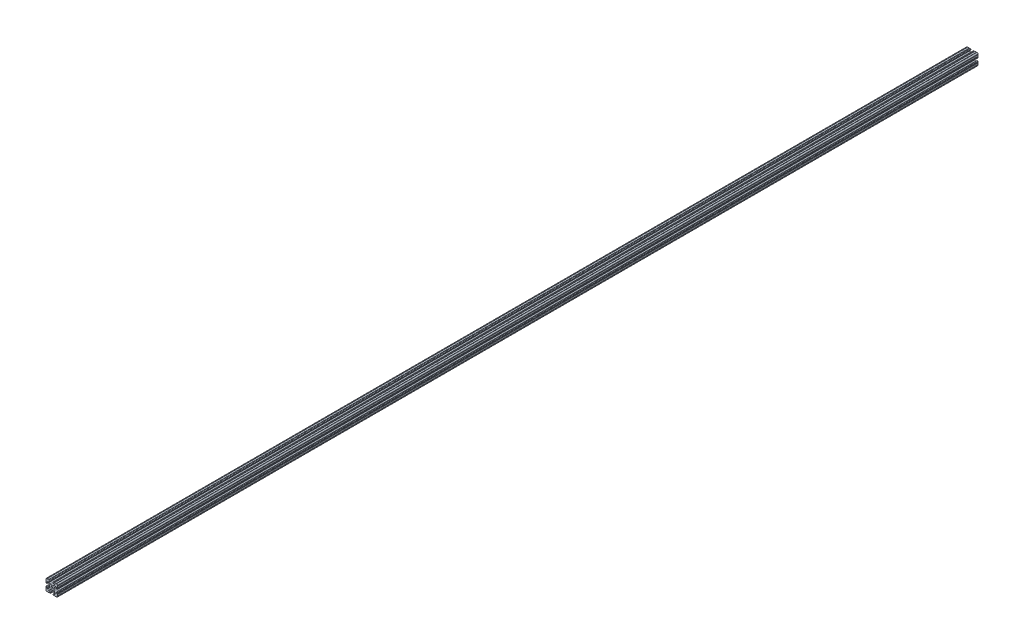
from build123d import *

# Parameters (mm, degrees)
SKETCH1_R           = 3.3274
BOSS_EXTRUDE1_DEPTH = 3048


with BuildPart() as part:
    # Sketch1 → Boss-Extrude1 (new body)
    with BuildSketch(Plane(origin=(0, 0, -304.8), x_dir=(-1, 0, 0), z_dir=(0, 0, -1))):
        with BuildLine():
            Line((14.327719208, 19.05), (9.498178705, 19.05))
            ThreePointArc((9.498178705, 19.05), (8.736178705, 18.288), (7.974178705, 19.05))
            Line((7.974178705, 19.05), (5.617617549, 19.05))
            ThreePointArc((5.617617549, 19.05), (4.519044045, 18.594955955), (4.064000001, 17.496382451))
            Line((4.064000001, 17.496382451), (4.064000001, 16.539617547))
            ThreePointArc((4.064000001, 16.539617547), (4.519044045, 15.441044043), (5.617617549, 14.985999999))
            Line((5.617617549, 14.985999999), (9.3853, 14.985999999))
            ThreePointArc((9.3853, 14.985999999), (10.022898185, 14.721898183), (10.287, 14.084299999))
            Line((10.287, 14.084299999), (10.287, 13.552357129))
            ThreePointArc((10.287, 13.552357129), (10.218362387, 13.207291991), (10.022898969, 12.914759729))
            Line((10.022898969, 12.914759729), (5.252158108, 8.144007131))
            ThreePointArc((5.252158108, 8.144007131), (3.715177374, 7.117027387), (1.902183977, 6.756399998))
            Line((1.902183977, 6.756399998), (-1.902183975, 6.756399998))
            ThreePointArc((-1.902183975, 6.756399998), (-3.715177372, 7.117027386), (-5.252158105, 8.14400713))
            Line((-5.252158105, 8.14400713), (-10.022898969, 12.914759729))
            ThreePointArc((-10.022898969, 12.914759729), (-10.218362387, 13.207291991), (-10.287, 13.55235713))
            Line((-10.287, 13.55235713), (-10.287, 14.084299999))
            ThreePointArc((-10.287, 14.084299999), (-10.022898185, 14.721898183), (-9.3853, 14.985999999))
            Line((-9.3853, 14.985999999), (-5.617617549, 14.985999999))
            ThreePointArc((-5.617617549, 14.985999999), (-4.519044045, 15.441044043), (-4.064000001, 16.539617547))
            Line((-4.064000001, 16.539617547), (-4.064000001, 17.496382451))
            ThreePointArc((-4.064000001, 17.496382451), (-4.519044045, 18.594955955), (-5.617617549, 19.05))
            Line((-5.617617549, 19.05), (-7.974178702, 19.05))
            ThreePointArc((-7.974178702, 19.05), (-8.736178702, 18.288), (-9.498178702, 19.05))
            Line((-9.498178702, 19.05), (-14.327719206, 19.05))
            ThreePointArc((-14.327719206, 19.05), (-15.087603121, 18.231251132), (-15.847487038, 19.05))
            ThreePointArc((-15.847487038, 19.05), (-18.120176287, 18.120192083), (-19.049999998, 15.847509295))
            ThreePointArc((-19.049999998, 15.847509295), (-18.23125099, 15.087625389), (-19.05, 14.327741484))
            Line((-19.05, 14.327741484), (-19.05, 9.49609147))
            ThreePointArc((-19.05, 9.49609147), (-18.23125099, 8.736207564), (-19.05, 7.976323659))
            Line((-19.05, 7.976323659), (-19.05, 5.617617549))
            ThreePointArc((-19.05, 5.617617549), (-18.594955955, 4.519044045), (-17.496382451, 4.064000001))
            Line((-17.496382451, 4.064000001), (-16.53961755, 4.064000001))
            ThreePointArc((-16.53961755, 4.064000001), (-15.441044046, 4.519044045), (-14.986000001, 5.617617549))
            Line((-14.986000001, 5.617617549), (-14.986000001, 9.385342517))
            ThreePointArc((-14.986000001, 9.385342517), (-14.721898186, 10.022940702), (-14.084300001, 10.287042517))
            Line((-14.084300001, 10.287042517), (-13.516042087, 10.287042517))
            ThreePointArc((-13.516042087, 10.287042517), (-13.170975923, 10.218404479), (-12.878443118, 10.022939917))
            Line((-12.878443118, 10.022939917), (-8.147580081, 5.292065242))
            ThreePointArc((-8.147580081, 5.292065242), (-7.11795588, 3.751120652), (-6.756400001, 1.933453584))
            Line((-6.756400001, 1.933453584), (-6.756400001, -1.933453584))
            ThreePointArc((-6.756400001, -1.933453584), (-7.11795588, -3.751120652), (-8.147580081, -5.292065242))
            Line((-8.147580081, -5.292065242), (-12.878443118, -10.022939917))
            ThreePointArc((-12.878443118, -10.022939917), (-13.170975923, -10.218404479), (-13.516042087, -10.287042517))
            Line((-13.516042087, -10.287042517), (-14.084300001, -10.287042517))
            ThreePointArc((-14.084300001, -10.287042517), (-14.721898186, -10.022940702), (-14.986000001, -9.385342517))
            Line((-14.986000001, -9.385342517), (-14.986000001, -5.617617549))
            ThreePointArc((-14.986000001, -5.617617549), (-15.441044046, -4.519044045), (-16.53961755, -4.064000001))
            Line((-16.53961755, -4.064000001), (-17.496382451, -4.064000001))
            ThreePointArc((-17.496382451, -4.064000001), (-18.594955955, -4.519044045), (-19.05, -5.617617549))
            Line((-19.05, -5.617617549), (-19.05, -7.97631849))
            ThreePointArc((-19.05, -7.97631849), (-18.23125099, -8.736202395), (-19.05, -9.496086301))
            Line((-19.05, -9.496086301), (-19.05, -14.327742909))
            ThreePointArc((-19.05, -14.327742909), (-18.23125099, -15.087626814), (-19.049999998, -15.84751072))
            ThreePointArc((-19.049999998, -15.84751072), (-18.120175716, -18.120192644), (-15.847486868, -19.050000001))
            ThreePointArc((-15.847486868, -19.050000001), (-15.087602952, -18.231251132), (-14.327719035, -19.05))
            Line((-14.327719035, -19.05), (-9.496062448, -19.05))
            ThreePointArc((-9.496062448, -19.05), (-8.736178532, -18.231251132), (-7.976294616, -19.05))
            Line((-7.976294616, -19.05), (-5.617617549, -19.05))
            ThreePointArc((-5.617617549, -19.05), (-4.519044045, -18.594955955), (-4.064000001, -17.496382451))
            Line((-4.064000001, -17.496382451), (-4.064000001, -16.53961755))
            ThreePointArc((-4.064000001, -16.53961755), (-4.519044045, -15.441044046), (-5.617617549, -14.986000001))
            Line((-5.617617549, -14.986000001), (-9.3853, -14.986000001))
            ThreePointArc((-9.3853, -14.986000001), (-10.022898185, -14.721898186), (-10.287, -14.084300001))
            Line((-10.287, -14.084300001), (-10.287, -13.552357132))
            ThreePointArc((-10.287, -13.552357132), (-10.218362387, -13.207291994), (-10.022898969, -12.914759732))
            Line((-10.022898969, -12.914759732), (-5.252158104, -8.144007133))
            ThreePointArc((-5.252158104, -8.144007133), (-3.715177371, -7.117027389), (-1.902183975, -6.756400001))
            Line((-1.902183975, -6.756400001), (1.902183978, -6.756400001))
            ThreePointArc((1.902183978, -6.756400001), (3.715177375, -7.117027389), (5.252158109, -8.144007134))
            Line((5.252158109, -8.144007134), (10.022898969, -12.914759732))
            ThreePointArc((10.022898969, -12.914759732), (10.218362387, -13.207291994), (10.287, -13.552357133))
            Line((10.287, -13.552357133), (10.287, -14.084300001))
            ThreePointArc((10.287, -14.084300001), (10.022898185, -14.721898186), (9.3853, -14.986000001))
            Line((9.3853, -14.986000001), (5.617617549, -14.986000001))
            ThreePointArc((5.617617549, -14.986000001), (4.519044045, -15.441044046), (4.064000001, -16.53961755))
            Line((4.064000001, -16.53961755), (4.064000001, -17.496382451))
            ThreePointArc((4.064000001, -17.496382451), (4.519044045, -18.594955955), (5.617617549, -19.05))
            Line((5.617617549, -19.05), (7.976294616, -19.05))
            ThreePointArc((7.976294616, -19.05), (8.736178532, -18.231251132), (9.496062448, -19.05))
            Line((9.496062448, -19.05), (14.327719035, -19.05))
            ThreePointArc((14.327719035, -19.05), (15.087602952, -18.231251132), (15.847486868, -19.050000001))
            ThreePointArc((15.847486868, -19.050000001), (18.120175717, -18.120192645), (19.050000001, -15.84751072))
            ThreePointArc((19.050000001, -15.84751072), (18.231250992, -15.087626816), (19.049999999, -14.327742909))
            Line((19.049999999, -14.327742909), (19.049999999, -9.496086301))
            ThreePointArc((19.049999999, -9.496086301), (18.231250991, -8.736202395), (19.049999999, -7.97631849))
            Line((19.049999999, -7.97631849), (19.049999999, -5.617617549))
            ThreePointArc((19.049999999, -5.617617549), (18.594955954, -4.519044045), (17.49638245, -4.064000001))
            Line((17.49638245, -4.064000001), (16.539617547, -4.064000001))
            ThreePointArc((16.539617547, -4.064000001), (15.441044043, -4.519044045), (14.985999999, -5.617617549))
            Line((14.985999999, -5.617617549), (14.985999999, -9.385342517))
            ThreePointArc((14.985999999, -9.385342517), (14.721898183, -10.022940702), (14.084299999, -10.287042517))
            Line((14.084299999, -10.287042517), (13.516042087, -10.287042517))
            ThreePointArc((13.516042087, -10.287042517), (13.170975924, -10.218404479), (12.878443118, -10.022939918))
            Line((12.878443118, -10.022939918), (8.147580079, -5.292065243))
            ThreePointArc((8.147580079, -5.292065243), (7.117955878, -3.751120653), (6.756399999, -1.933453584))
            Line((6.756399999, -1.933453584), (6.756399999, 1.933453584))
            ThreePointArc((6.756399999, 1.933453584), (7.117955878, 3.751120653), (8.147580079, 5.292065243))
            Line((8.147580079, 5.292065243), (12.878443118, 10.022939918))
            ThreePointArc((12.878443118, 10.022939918), (13.170975924, 10.218404479), (13.516042087, 10.287042517))
            Line((13.516042087, 10.287042517), (14.084299999, 10.287042517))
            ThreePointArc((14.084299999, 10.287042517), (14.721898183, 10.022940702), (14.985999999, 9.385342517))
            Line((14.985999999, 9.385342517), (14.985999999, 5.617617549))
            ThreePointArc((14.985999999, 5.617617549), (15.441044043, 4.519044045), (16.539617547, 4.064000001))
            Line((16.539617547, 4.064000001), (17.49638245, 4.064000001))
            ThreePointArc((17.49638245, 4.064000001), (18.594955954, 4.519044045), (19.049999999, 5.617617549))
            Line((19.049999999, 5.617617549), (19.049999999, 7.976323659))
            ThreePointArc((19.049999999, 7.976323659), (18.231250991, 8.736207564), (19.049999999, 9.49609147))
            Line((19.049999999, 9.49609147), (19.049999999, 14.327741484))
            ThreePointArc((19.049999999, 14.327741484), (18.231250992, 15.087625391), (19.050000001, 15.847509295))
            ThreePointArc((19.050000001, 15.847509295), (18.12017629, 18.120192083), (15.84748704, 19.05))
            ThreePointArc((15.84748704, 19.05), (15.087603124, 18.231251132), (14.327719208, 19.05))
        make_face()
        Circle(SKETCH1_R, mode=Mode.SUBTRACT)
    extrude(amount=-BOSS_EXTRUDE1_DEPTH)


solid = part.part
